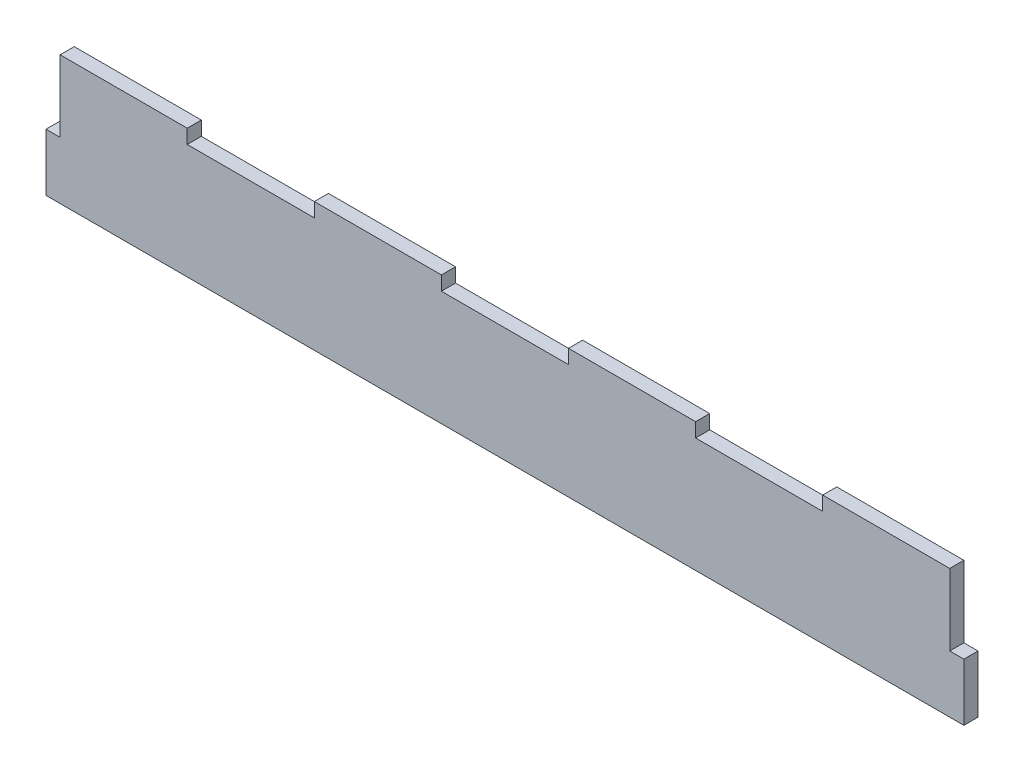
from build123d import *

# Parameters (mm, degrees)
SKETCH1_W           = 10.16
SKETCH1_H           = 41.275
SKETCH1_W_2         = 91.44
SKETCH1_H_2         = 10.16
BOSS_EXTRUDE1_DEPTH = 10.16


with BuildPart() as part:
    # Sketch1 → Boss-Extrude1 (new body)
    with BuildSketch(Plane.XY):
        Polygon((193.04, -10.16), (101.6, -10.16), (10.16, -10.16), (10.16, -51.435), (10.16, -92.71), (650.24, -92.71), (650.24, -51.435), (650.24, -10.16), (558.8, -10.16), (467.36, -10.16), (375.92, -10.16), (284.48, -10.16), align=None)
        with Locations((655.32, -72.0725)):
            Rectangle(SKETCH1_W, SKETCH1_H)
        with Locations((604.52, -5.08)):
            Rectangle(SKETCH1_W_2, SKETCH1_H_2)
        with Locations((421.64, -5.08)):
            Rectangle(SKETCH1_W_2, SKETCH1_H_2)
        with Locations((238.76, -5.08)):
            Rectangle(SKETCH1_W_2, SKETCH1_H_2)
        with Locations((55.88, -5.08)):
            Rectangle(SKETCH1_W_2, SKETCH1_H_2)
        with Locations((5.08, -72.0725)):
            Rectangle(SKETCH1_W, SKETCH1_H)
    extrude(amount=BOSS_EXTRUDE1_DEPTH)


solid = part.part
